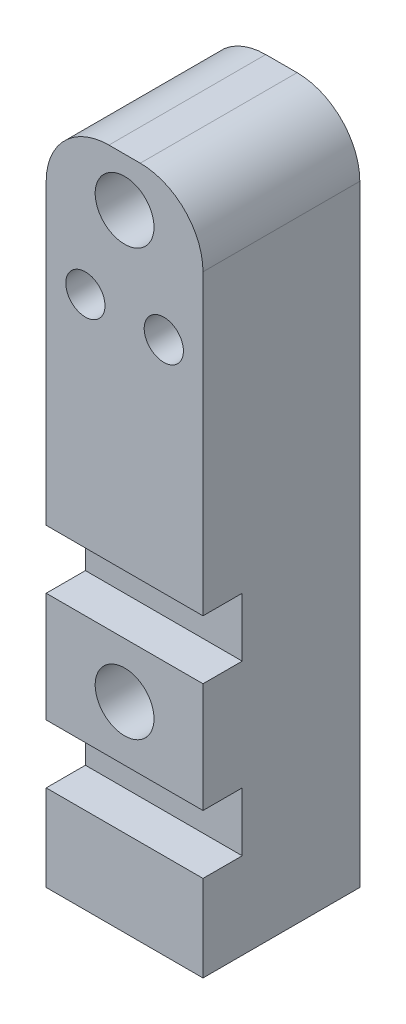
from build123d import *

# Parameters (mm, degrees)
SKETCH1_R           = 4.7625
SKETCH1_R_2         = 3.175
BOSS_EXTRUDE1_DEPTH = 25.4
SKETCH1_3_R         = 4.7625
CUT_EXTRUDE1_DEPTH  = 16.51
SKETCH2_R           = 3.175
CUT_EXTRUDE2_DEPTH  = 17.78
SKETCH3_W           = 25.4
SKETCH3_H           = 9.525
CUT_EXTRUDE3_DEPTH  = 6.35


with BuildPart() as part:
    # Sketch1 → Boss-Extrude1 (new body)
    with BuildSketch(Plane.XY):
        with BuildLine():
            ThreePointArc((-12.7, 99.06), (-9.724204897, 106.244204897), (-2.54, 109.22))
            Line((-2.54, 109.22), (2.54, 109.22))
            ThreePointArc((2.54, 109.22), (9.724204897, 106.244204897), (12.7, 99.06))
            Line((12.7, 99.06), (12.7, 0))
            Line((12.7, 0), (-12.7, 0))
            Line((-12.7, 0), (-12.7, 99.06))
        make_face()
        with Locations((0, 101.346)):
            Circle(SKETCH1_R, mode=Mode.SUBTRACT)
        with Locations((6.35, 86.36)):
            Circle(SKETCH1_R_2, mode=Mode.SUBTRACT)
        with Locations((-6.35, 86.36)):
            Circle(SKETCH1_R_2, mode=Mode.SUBTRACT)
        with Locations((0, 32.385)):
            Circle(SKETCH1_R, mode=Mode.SUBTRACT)
        with Locations((0, 101.346)):
            Circle(SKETCH1_R)
    extrude(amount=-BOSS_EXTRUDE1_DEPTH)

    # Sketch1_3 → Cut-Extrude1 (cut)
    with BuildSketch(Plane.XY):
        with Locations((0, 101.346)):
            Circle(SKETCH1_3_R)
    extrude(amount=-CUT_EXTRUDE1_DEPTH, mode=Mode.SUBTRACT)

    # Sketch2 → Cut-Extrude2 (cut)
    with BuildSketch(Plane.XZ):
        with Locations((0, -12.7)):
            Circle(SKETCH2_R)
    extrude(amount=-CUT_EXTRUDE2_DEPTH, mode=Mode.SUBTRACT)

    # Sketch3 → Cut-Extrude3 (cut)
    with BuildSketch(Plane.XY):
        with Locations((0, 46.0375)):
            Rectangle(SKETCH3_W, SKETCH3_H)
        with Locations((0, 18.7325)):
            Rectangle(SKETCH3_W, SKETCH3_H)
    extrude(amount=-CUT_EXTRUDE3_DEPTH, mode=Mode.SUBTRACT)


solid = part.part
